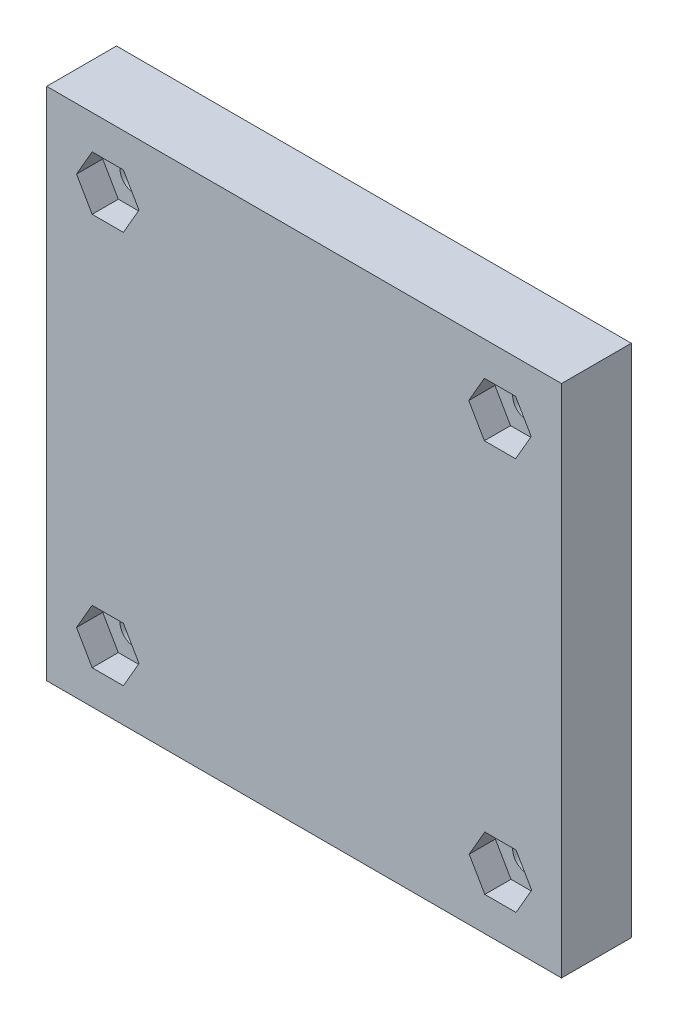
from build123d import *

# Parameters (mm, degrees)
SKIZZE1_W                        = 59
SKIZZE1_H                        = 59
AUFSATZ_LINEAR_AUSTRAGEN1_DEPTH  = 8
WANDUNG4_T                       = -2
SKIZZE5_W                        = 10
SKIZZE5_H                        = 10
AUFSATZ_LINEAR_AUSTRAGEN2_DEPTH  = 4
SKIZZE3_R                        = 1.6
SCHNITT_LINEAR_AUSTRAGEN8_DEPTH  = 10
SKIZZE6_W                        = 3.5
SKIZZE6_H                        = 10
SCHNITT_LINEAR_AUSTRAGEN10_DEPTH = 2
SCHNITT_LINEAR_AUSTRAGEN11_DEPTH = 3


with BuildPart() as part:
    # Skizze1 → Aufsatz-Linear austragen1 (new body)
    with BuildSketch(Plane.XY):
        Rectangle(SKIZZE1_W, SKIZZE1_H)
    extrude(amount=AUFSATZ_LINEAR_AUSTRAGEN1_DEPTH)

    # Wandung4
    wandung4_openings = [part.faces().sort_by_distance(p)[0] for p in [
        (0, 0, 0),
    ]]
    offset(amount=WANDUNG4_T, openings=wandung4_openings, kind=Kind.INTERSECTION)

    # Skizze5 → Aufsatz-Linear austragen2 (add)
    with BuildSketch(Plane(origin=(0, 0, 6), x_dir=(-1, 0, 0), z_dir=(0, 0, -1))):
        with Locations((-22.5, 22.5)):
            Rectangle(SKIZZE5_W, SKIZZE5_H)
        with Locations((22.5, 22.5)):
            Rectangle(SKIZZE5_W, SKIZZE5_H)
        with Locations((-22.5, -22.5)):
            Rectangle(SKIZZE5_W, SKIZZE5_H)
        with Locations((22.5, -22.5)):
            Rectangle(SKIZZE5_W, SKIZZE5_H)
    extrude(amount=AUFSATZ_LINEAR_AUSTRAGEN2_DEPTH)

    # Skizze3 → Schnitt-Linear austragen8 (cut)
    with BuildSketch(Plane.XY):
        with Locations((22.5, 22.5)):
            Circle(SKIZZE3_R)
        with Locations((-22.5, 22.5)):
            Circle(SKIZZE3_R)
        with Locations((-22.5, -22.5)):
            Circle(SKIZZE3_R)
        with Locations((22.5, -22.5)):
            Circle(SKIZZE3_R)
    extrude(amount=SCHNITT_LINEAR_AUSTRAGEN8_DEPTH, mode=Mode.SUBTRACT)

    # Skizze6 → Schnitt-Linear austragen10 (cut)
    with BuildSketch(Plane.ZY.offset(29.5)):
        with Locations((4.25, 4.5)):
            Rectangle(SKIZZE6_W, SKIZZE6_H)
    extrude(amount=-SCHNITT_LINEAR_AUSTRAGEN10_DEPTH, mode=Mode.SUBTRACT)

    # Skizze7 → Schnitt-Linear austragen11 (cut)
    with BuildSketch(Plane.XY.offset(8)):
        Polygon((-20.710214166, 25.6), (-24.289785834, 25.6), (-26.079571669, 22.5), (-24.289785834, 19.4), (-20.710214166, 19.4), (-18.920428331, 22.5), align=None)
        Polygon((24.237900311, 25.6), (20.658328642, 25.6), (18.868542808, 22.5), (20.658328642, 19.4), (24.237900311, 19.4), (26.027686146, 22.5), align=None)
        Polygon((-18.920428331, -22.5), (-20.710214166, -19.4), (-24.289785834, -19.4), (-26.079571669, -22.5), (-24.289785834, -25.6), (-20.710214166, -25.6), align=None)
        Polygon((24.289785834, -19.4), (20.710214166, -19.4), (18.920428331, -22.5), (20.710214166, -25.6), (24.289785834, -25.6), (26.079571669, -22.5), align=None)
    extrude(amount=-SCHNITT_LINEAR_AUSTRAGEN11_DEPTH, mode=Mode.SUBTRACT)


solid = part.part
